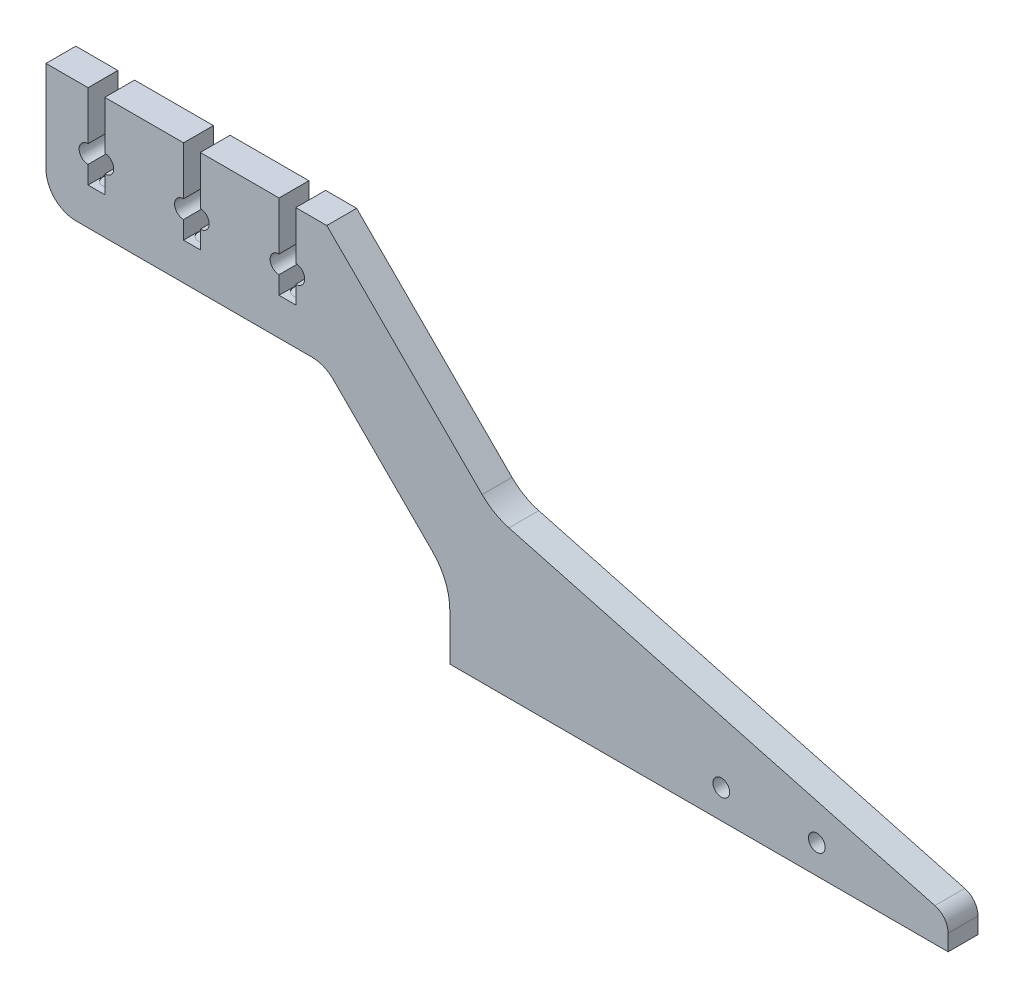
from build123d import *

# Parameters (mm, degrees)
SKETCH_1_R          = 1.4
EXTRUDE_1_DEPTH     = 2.5
SKETCH_2_R          = 1.4
CUT_EXTRUDE_1_DEPTH = 0.1


with BuildPart() as part:
    # 草图1 → 凸台-拉伸1 (new body, symmetric)
    with BuildSketch(Plane.XY):
        with BuildLine():
            Line((-57.805032963, 53.332573096), (-44.605032963, 53.332573096))
            Line((-44.605032963, 53.332573096), (-44.605032963, 45.206973096))
            ThreePointArc((-44.605032963, 45.206973096), (-46.105032963, 43.706973096), (-44.605032963, 42.206973096))
            Line((-44.605032963, 42.206973096), (-44.605032963, 39.206973096))
            Line((-44.605032963, 39.206973096), (-41.805032963, 39.206973096))
            Line((-41.805032963, 39.206973096), (-41.805032963, 42.206973096))
            ThreePointArc((-41.805032963, 42.206973096), (-40.305032963, 43.706973096), (-41.805032963, 45.206973096))
            Line((-41.805032963, 45.206973096), (-41.805032963, 53.332573096))
            Line((-41.805032963, 53.332573096), (-28.605032963, 53.332573096))
            Line((-28.605032963, 53.332573096), (-28.605032963, 45.206973096))
            ThreePointArc((-28.605032963, 45.206973096), (-30.105032963, 43.706973096), (-28.605032963, 42.206973096))
            Line((-28.605032963, 42.206973096), (-28.605032963, 39.206973096))
            Line((-28.605032963, 39.206973096), (-25.805032963, 39.206973096))
            Line((-25.805032963, 39.206973096), (-25.805032963, 42.206973096))
            ThreePointArc((-25.805032963, 42.206973096), (-24.305032963, 43.706973096), (-25.805032963, 45.206973096))
            Line((-25.805032963, 45.206973096), (-25.805032963, 53.332573096))
            Line((-25.805032963, 53.332573096), (-20.605032963, 53.332573096))
            Line((-20.605032963, 53.332573096), (5.420799629, 27.306740503))
            ThreePointArc((5.420799629, 27.306740503), (7.491867441, 25.717554277), (9.90367699, 24.718550052))
            Line((9.90367699, 24.718550052), (81.270764772, 5.595796515))
            ThreePointArc((81.270764772, 5.595796515), (82.874367658, 4.524303323), (83.494307637, 2.698019036))
            Line((83.494307637, 2.698019036), (83.494307637, 0))
            Line((83.494307637, 0), (0, 0))
            Line((0, 0), (0, 7.857864376))
            ThreePointArc((0, 7.857864376), (-0.761204675, 11.6846987), (-2.928932188, 14.928932188))
            Line((-2.928932188, 14.928932188), (-19.524740269, 31.524740269))
            ThreePointArc((-19.524740269, 31.524740269), (-21.146857013, 32.608604026), (-23.060274175, 32.989206363))
            Line((-23.060274175, 32.989206363), (-62.648227072, 32.989206363))
            ThreePointArc((-62.648227072, 32.989206363), (-66.183760977, 34.453672457), (-67.648227072, 37.989206363))
            Line((-67.648227072, 37.989206363), (-67.648227072, 53.332573096))
            Line((-67.648227072, 53.332573096), (-60.605032963, 53.332573096))
            Line((-60.605032963, 53.332573096), (-60.605032963, 45.206973096))
            ThreePointArc((-60.605032963, 45.206973096), (-62.105032963, 43.706973096), (-60.605032963, 42.206973096))
            Line((-60.605032963, 42.206973096), (-60.605032963, 39.206973096))
            Line((-60.605032963, 39.206973096), (-57.805032963, 39.206973096))
            Line((-57.805032963, 39.206973096), (-57.805032963, 42.206973096))
            ThreePointArc((-57.805032963, 42.206973096), (-56.305032963, 43.706973096), (-57.805032963, 45.206973096))
            Line((-57.805032963, 45.206973096), (-57.805032963, 53.332573096))
        make_face()
        with Locations((45.49026085, 4.838412731)):
            Circle(SKETCH_1_R, mode=Mode.SUBTRACT)
        with Locations((61.49026085, 4.838412731)):
            Circle(SKETCH_1_R, mode=Mode.SUBTRACT)
    extrude(amount=EXTRUDE_1_DEPTH, both=True)

    # 草图2 → 切除-拉伸1 (cut)
    with BuildSketch(Plane(origin=(0, 39.206973096, 0), x_dir=(1, 0, 0), z_dir=(0, 1, 0))):
        with Locations((-59.205032963, 0)):
            Circle(SKETCH_2_R)
        with Locations((-43.205032963, 0)):
            Circle(SKETCH_2_R)
        with Locations((-27.205032963, 0)):
            Circle(SKETCH_2_R)
    extrude(amount=-CUT_EXTRUDE_1_DEPTH, mode=Mode.SUBTRACT)


solid = part.part
